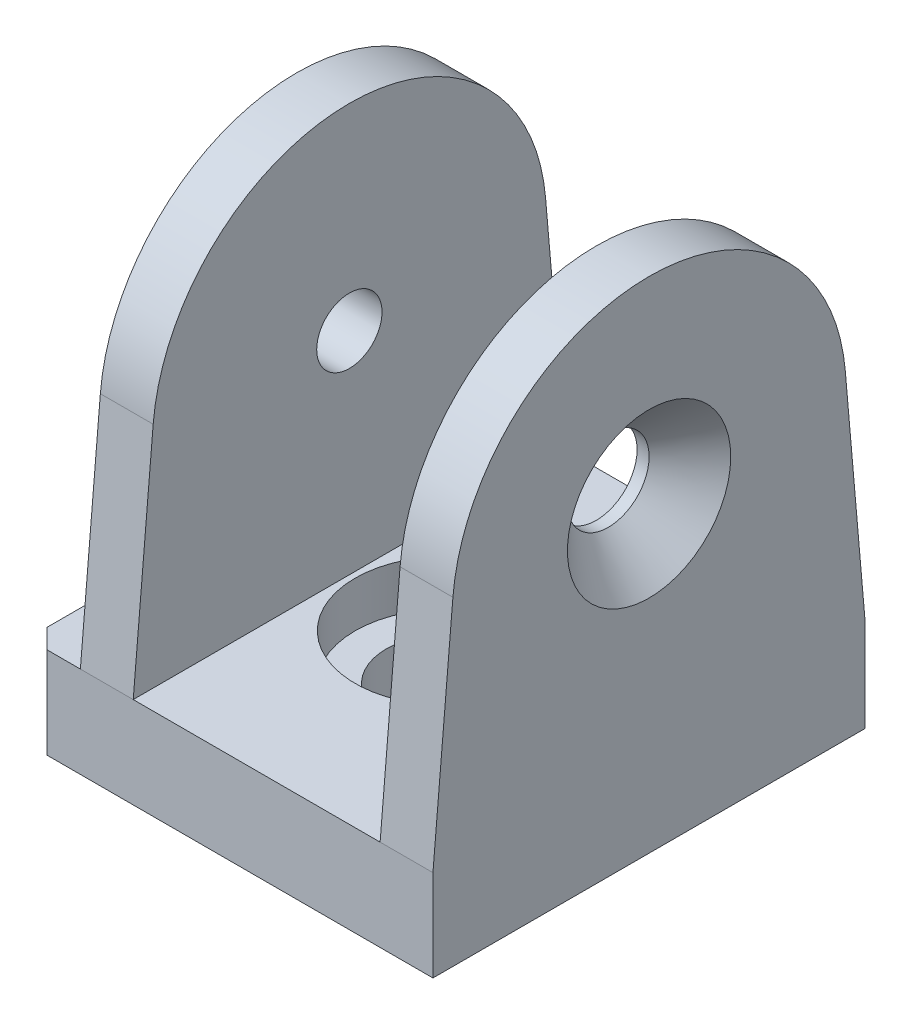
from build123d import *

# Parameters (mm, degrees)
SKETCH_1_W               = 42.2
SKETCH_1_H               = 45
EXTRUDE_1_DEPTH          = 9.5
EXTRUDE_2_DEPTH          = 36.7
SKETCH_4_W               = 25.7
SKETCH_4_H               = 42.5
CUT_EXTRUDE_1_DEPTH      = 23.5
CUT_EXTRUDE_1_DEPTH_BACK = 23.5
CHAMFER_1_SIZE           = 2
HOLE_WIZARD_M81_2_D      = 6.8
HOLE_WIZARD_M81_2_DEPTH  = 5.5


with BuildPart() as part:
    # Эскиз1 → Бобышка-Вытянуть1 (new body)
    with BuildSketch(Plane(origin=(0, 0, 0), x_dir=(1, 0, 0), z_dir=(0, 1, 0))):
        Rectangle(SKETCH_1_W, SKETCH_1_H)
    extrude(amount=EXTRUDE_1_DEPTH)

    # Эскиз2 → Вырез-Повернуть1 (revolve, cut)
    with BuildSketch(Plane.XY):
        Polygon((-6.25, 0), (-6.25, 4.75), (-9.5, 4.75), (-9.5, 9.5), (0, 9.5), (0, 0), align=None)
    revolve(axis=Axis((0, 9.5, 0), (0, -1, 0)), mode=Mode.SUBTRACT)

    # Эскиз3 → Бобышка-Вытянуть2 (add)
    with BuildSketch(Plane(origin=(21.1, 0, 0), x_dir=(0, 0, -1), z_dir=(1, 0, 0))):
        with BuildLine():
            Line((-22.5, 9.5), (-20.422219056, 33.284087671))
            ThreePointArc((-20.422219056, 33.284087671), (0, 52), (20.422219056, 33.284087671))
            Line((20.422219056, 33.284087671), (22.5, 9.5))
            Line((22.5, 9.5), (-22.5, 9.5))
        make_face()
    extrude(amount=-EXTRUDE_2_DEPTH)

    # Эскиз4 → Вырез-Вытянуть1 (cut, two sides)
    with BuildSketch(Plane.XY) as cut_extrude_1_sk:
        with Locations((2.75, 30.75)):
            Rectangle(SKETCH_4_W, SKETCH_4_H)
    extrude(amount=CUT_EXTRUDE_1_DEPTH, mode=Mode.SUBTRACT)
    extrude(cut_extrude_1_sk.sketch, amount=-CUT_EXTRUDE_1_DEPTH_BACK, mode=Mode.SUBTRACT)

    # Фаска1
    chamfer_1_edges = [part.edges().sort_by_distance(p)[0] for p in [
        (-21.1, 4.75, -22.5),
        (-21.1, 4.75, 22.5),
    ]]
    chamfer(chamfer_1_edges, length=CHAMFER_1_SIZE)

    # Эскиз10 → Hole Wizard M81 (revolve, cut)
    with BuildSketch(Plane(origin=(21.1, 31.5, 0), x_dir=(0, 0, -1), z_dir=(0, 1, 0))):
        Polygon((0, 0), (0, 5.5), (4.25, 5.5), (4.25, 4.25), (8.5, 0), align=None)
    revolve(axis=Axis((27.45, 31.5, 0), (-1, 0, 0)), mode=Mode.SUBTRACT)

    # Hole Wizard M81 2
    with Locations(Plane.ZY.offset(15.6)):
        with Locations((0, 31.5)):
            Hole(HOLE_WIZARD_M81_2_D / 2, depth=HOLE_WIZARD_M81_2_DEPTH)


solid = part.part
